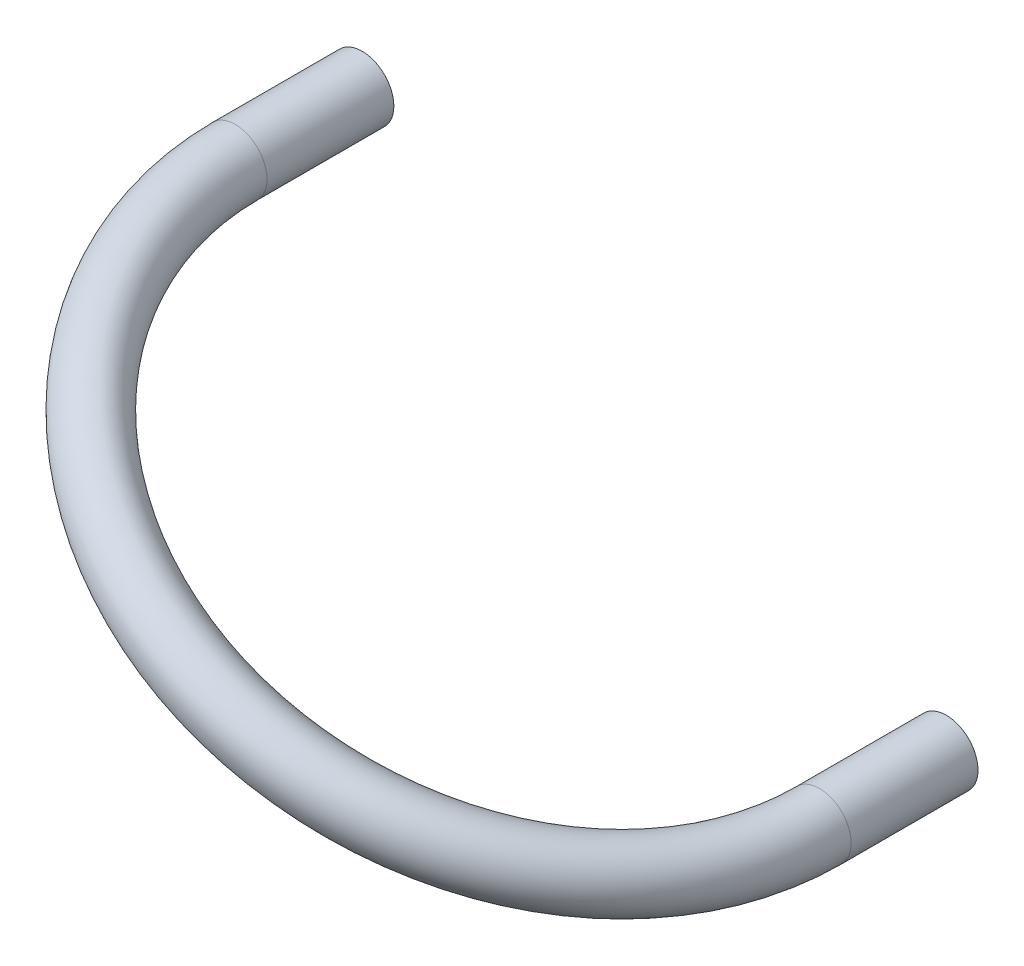
from build123d import *

# Parameters (mm, degrees)
SWEEP_THIN1_PROFILE_R   = 4.7625
SWEEP_THIN1_PROFILE_R_2 = 2.7625


with BuildPart() as part:
    # Sweep-Thin1: sweep along a curve in space
    with BuildLine() as sweep_thin1_path:
        Line((-133.107305448, 76.245, -50.08), (-133.107305448, 76.245, -69.13))
        ThreePointArc((-45.3749896, 33.75, -50.08), (-89.241147524, 54.9975, -1.3388873), (-133.107305448, 76.245, -50.08))
        Line((-45.3749896, 33.75, -50.08), (-45.3749896, 33.75, -69.13))
    # Sweep-Thin1 profile (on start of the path) → Sweep-Thin1 (sweep)
    with BuildSketch(Plane(origin=(-45.3749896, 33.75, -69.13), x_dir=(1, 0, 0), z_dir=(0, 0, 1))):
        Circle(SWEEP_THIN1_PROFILE_R)
        Circle(SWEEP_THIN1_PROFILE_R_2, mode=Mode.SUBTRACT)
    sweep(path=sweep_thin1_path.line)


solid = part.part
